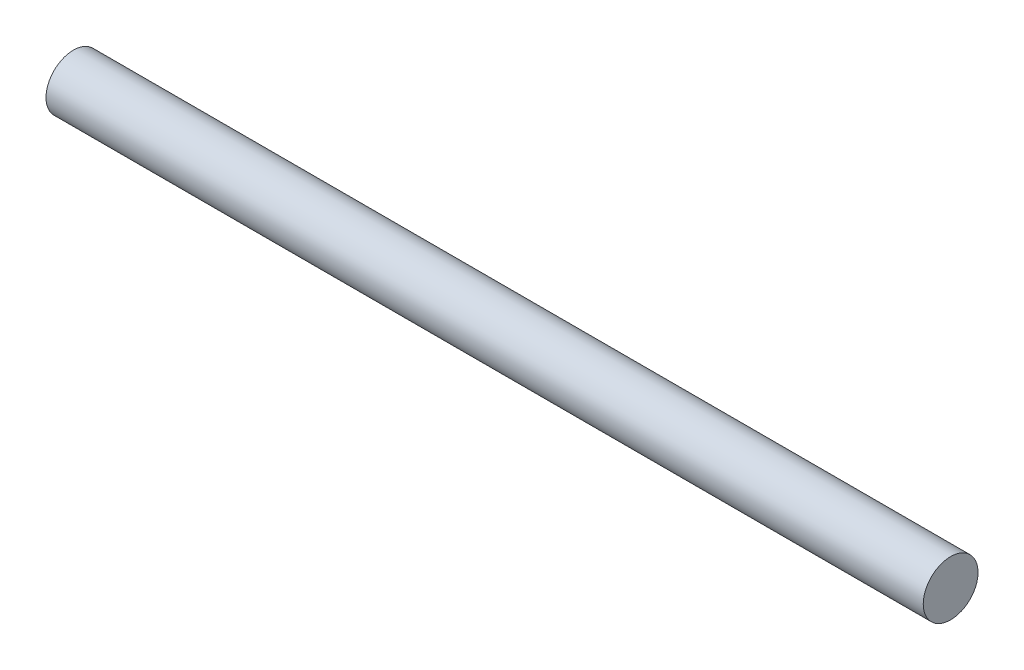
from build123d import *

# Parameters (mm, degrees)
SKETCH_1_W = 480
SKETCH_1_H = 15


with BuildPart() as part:
    # 草图1 → 旋转1 (revolve)
    with BuildSketch(Plane.XY):
        with Locations((240, 7.5)):
            Rectangle(SKETCH_1_W, SKETCH_1_H)
    revolve(axis=Axis((0, 0, 0), (1, 0, 0)))


solid = part.part
